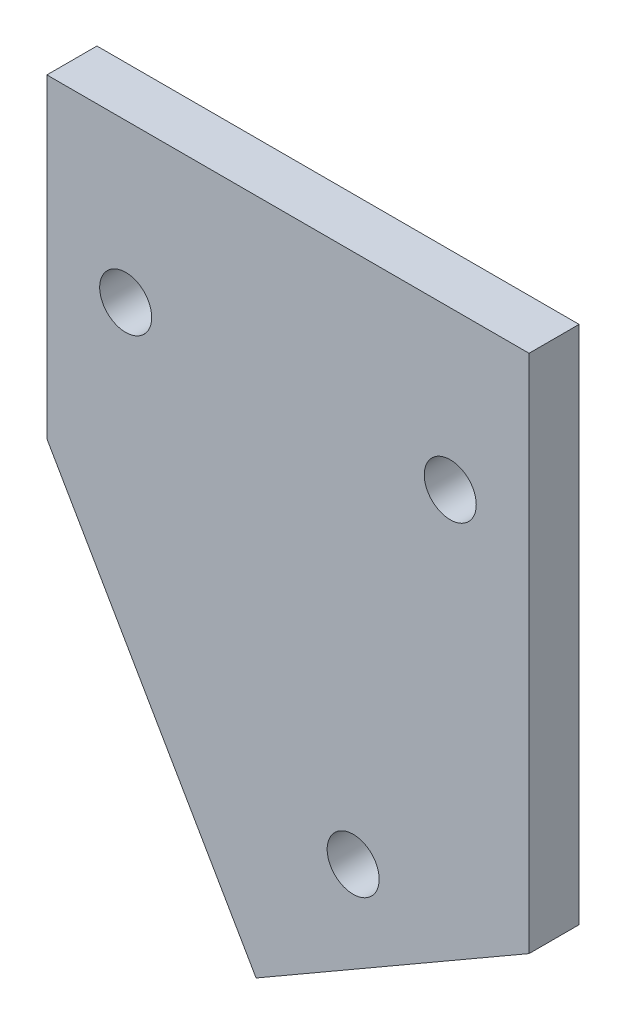
from build123d import *

# Parameters (mm, degrees)
SKETCH1_R           = 1.65
BOSS_EXTRUDE1_DEPTH = 3.175


with BuildPart() as part:
    # Sketch1 → Boss-Extrude1 (new body)
    with BuildSketch(Plane.XY):
        Polygon((0, 0), (13.273502692, -22.990381057), (30.594010768, -12.990381057), (30.594010768, 20), (0, 20), align=None)
        with Locations((19.43375673, -13.660254038)):
            Circle(SKETCH1_R, mode=Mode.SUBTRACT)
        with Locations((5, 10)):
            Circle(SKETCH1_R, mode=Mode.SUBTRACT)
        with Locations((25.594010768, 10)):
            Circle(SKETCH1_R, mode=Mode.SUBTRACT)
    extrude(amount=BOSS_EXTRUDE1_DEPTH)


solid = part.part
